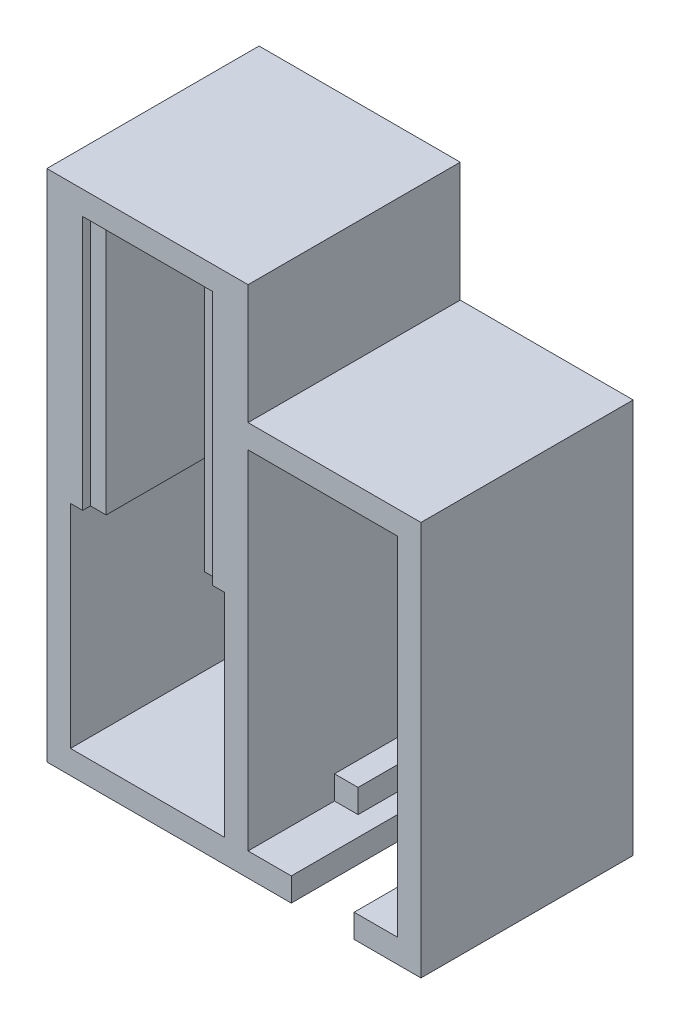
from build123d import *

# Parameters (mm, degrees)
BOSS_EXTRUDE1_DEPTH = 3
BOSS_EXTRUDE2_DEPTH = 27
SKETCH1_4_W         = 3
SKETCH1_4_H         = 3
SKETCH1_4_W_2       = 5
BOSS_EXTRUDE3_DEPTH = 16
SKETCH1_5_W         = 8
SKETCH1_5_H         = 3
BOSS_EXTRUDE4_DEPTH = 11
SKETCH1_6_W         = 2
SKETCH1_6_H         = 32.4
BOSS_EXTRUDE5_DEPTH = 26


with BuildPart() as part:
    # Sketch1 → Boss-Extrude1 (new body)
    with BuildSketch(Plane.XY):
        Polygon((-25.6, -3), (22, -3), (22, 47.2), (0, 47.2), (0, 62.4), (-25.6, 62.4), align=None)
    extrude(amount=BOSS_EXTRUDE1_DEPTH)

    # Sketch1_3 → Boss-Extrude2 (add)
    with BuildSketch(Plane.XY):
        Polygon((-25.6, -3), (5.5, -3), (5.5, 0), (0, 0), (0, 44.2), (19, 44.2), (19, 0), (13.5, 0), (13.5, -3), (22, -3), (22, 47.2), (0, 47.2), (0, 62.4), (-25.6, 62.4), align=None)
        Polygon((-3, 27), (-3, 0), (-22.6, 0), (-22.6, 27), (-21.05, 27), (-21.05, 59.4), (-4.55, 59.4), (-4.55, 27), align=None, mode=Mode.SUBTRACT)
    extrude(amount=BOSS_EXTRUDE2_DEPTH)

    # Sketch1_4 → Boss-Extrude3 (add)
    with BuildSketch(Plane.XY):
        with Locations((1.5, 1.5)):
            Rectangle(SKETCH1_4_W, SKETCH1_4_H)
        with Locations((2.5, 42.7)):
            Rectangle(SKETCH1_4_W_2, SKETCH1_4_H)
        with Locations((17.5, 1.5)):
            Rectangle(SKETCH1_4_W, SKETCH1_4_H)
        with Locations((16.5, 42.7)):
            Rectangle(SKETCH1_4_W_2, SKETCH1_4_H)
    extrude(amount=BOSS_EXTRUDE3_DEPTH)

    # Sketch1_5 → Boss-Extrude4 (add)
    with BuildSketch(Plane.XY):
        with Locations((9.5, -1.5)):
            Rectangle(SKETCH1_5_W, SKETCH1_5_H)
    extrude(amount=BOSS_EXTRUDE4_DEPTH)

    # Sketch1_6 → Boss-Extrude5 (add)
    with BuildSketch(Plane.XY):
        with Locations((-5.55, 43.2)):
            Rectangle(SKETCH1_6_W, SKETCH1_6_H)
        with Locations((-20.05, 43.2)):
            Rectangle(SKETCH1_6_W, SKETCH1_6_H)
    extrude(amount=BOSS_EXTRUDE5_DEPTH)


solid = part.part
